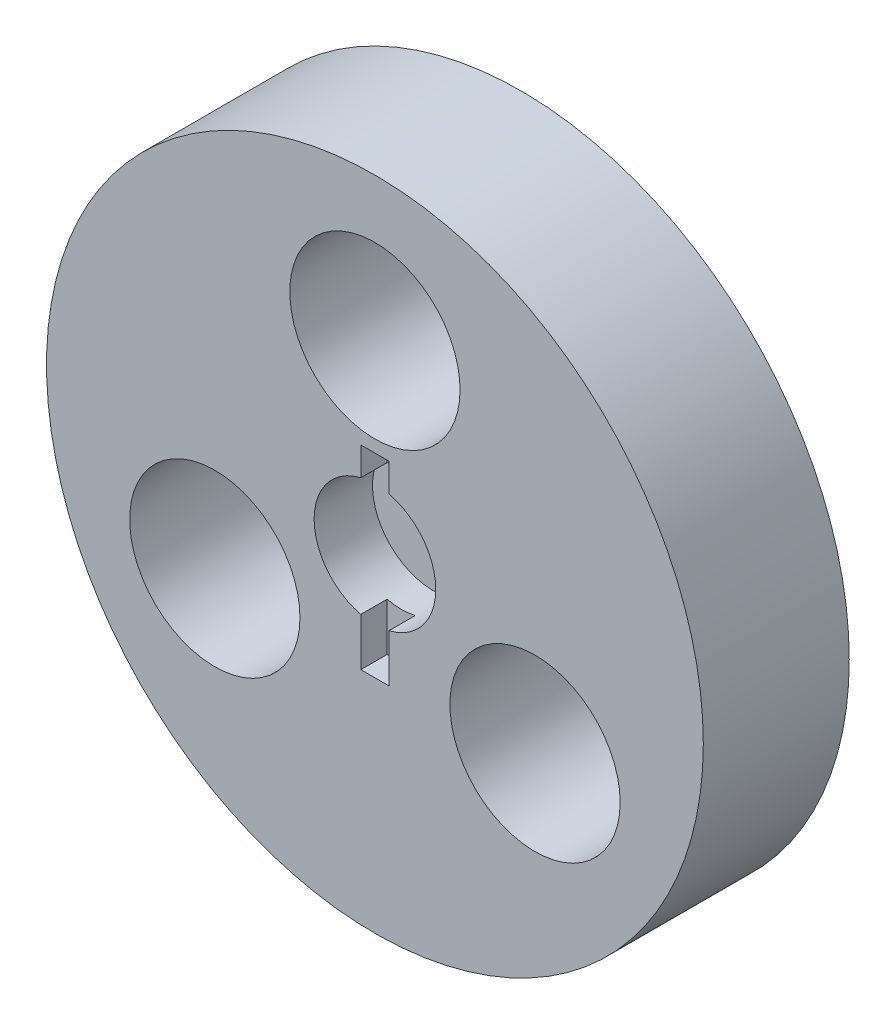
from build123d import *

# Parameters (mm, degrees)
SKETCH1_R           = 42.8625
SKETCH1_R_2         = 11.1125
BOSS_EXTRUDE1_DEPTH = 9.525
SKETCH2_R           = 7.9375
CUT_EXTRUDE1_DEPTH  = 7.62
SKETCH3_W           = 3.683
SKETCH3_H           = 25.4
CUT_EXTRUDE2_DEPTH  = 3.429


with BuildPart() as part:
    # Sketch1 → Boss-Extrude1 (new body, symmetric)
    with BuildSketch(Plane.XY):
        Circle(SKETCH1_R)
        with Locations((0, 24.13)):
            Circle(SKETCH1_R_2, mode=Mode.SUBTRACT)
        with Locations((-20.897192993, -12.065)):
            Circle(SKETCH1_R_2, mode=Mode.SUBTRACT)
        with Locations((20.897192993, -12.065)):
            Circle(SKETCH1_R_2, mode=Mode.SUBTRACT)
    extrude(amount=BOSS_EXTRUDE1_DEPTH, both=True)

    # Sketch2 → Cut-Extrude1 (cut)
    with BuildSketch(Plane.XY.offset(9.525)):
        Circle(SKETCH2_R)
    extrude(amount=-CUT_EXTRUDE1_DEPTH, mode=Mode.SUBTRACT)

    # Sketch3 → Cut-Extrude2 (cut)
    with BuildSketch(Plane.XY.offset(9.525)):
        with Locations((0, -1.27)):
            Rectangle(SKETCH3_W, SKETCH3_H)
    extrude(amount=-CUT_EXTRUDE2_DEPTH, mode=Mode.SUBTRACT)


solid = part.part
